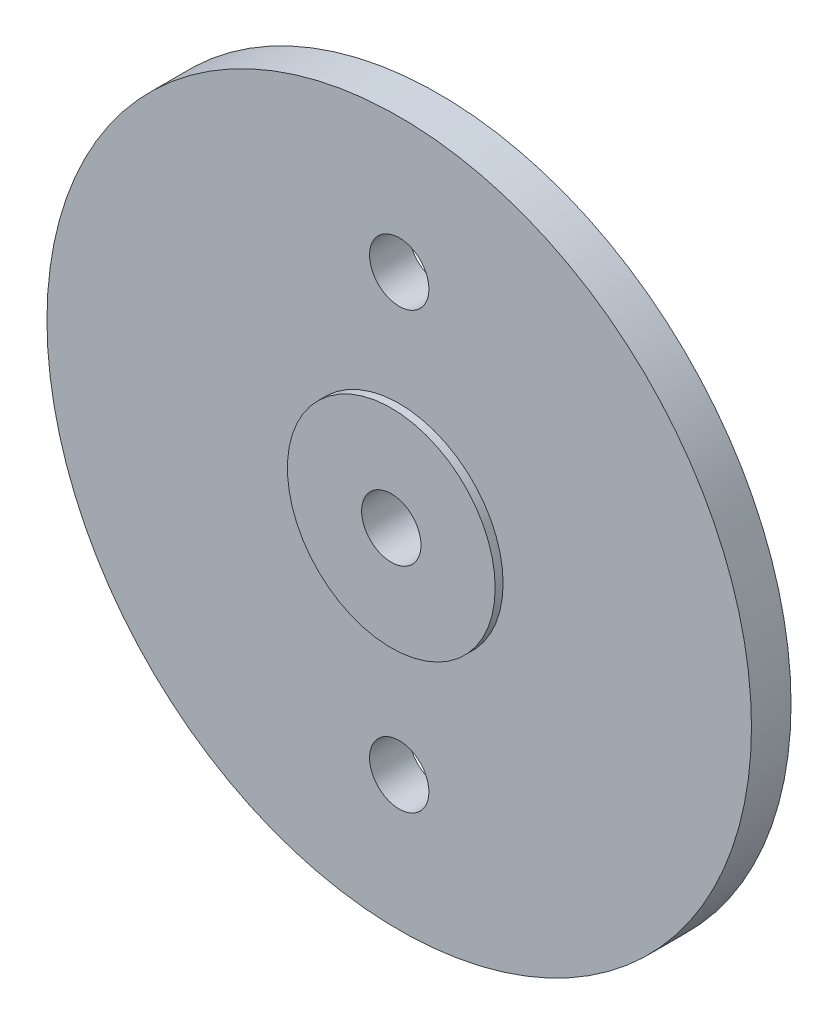
from build123d import *

# Parameters (mm, degrees)
SKETCH_1_R          = 17.8
EXTRUDE_1_DEPTH     = 2
SKETCH_2_R          = 7.85
EXTRUDE_2_DEPTH     = 0.8
DRAFT_1_ANGLE       = 1
SKETCH_38_R         = 4.8
EXTRUDE_3_DEPTH     = 1.9
SKETCH_39_R         = 5.25
EXTRUDE_4_DEPTH     = 0.4
SKETCH_40_R         = 1.5
CUT_EXTRUDE_1_DEPTH = 10.4
SKETCH_42_R         = 1.5
CUT_EXTRUDE_3_DEPTH = 10


with BuildPart() as part:
    # ｽｹｯﾁ1 → ﾎﾞｽ - 押し出し1 (new body)
    with BuildSketch(Plane.XY):
        Circle(SKETCH_1_R)
    extrude(amount=EXTRUDE_1_DEPTH)

    # ｽｹｯﾁ2 → ﾎﾞｽ - 押し出し2 (add)
    with BuildSketch(Plane(origin=(0, 0, 0), x_dir=(-1, 0, 0), z_dir=(0, 0, -1))):
        Circle(SKETCH_2_R)
    extrude(amount=EXTRUDE_2_DEPTH)

    # 抜き勾配1
    draft_1_faces = [part.faces().sort_by_distance(p)[0] for p in [
        (7.85, 0, -0.4),
    ]]
    draft(draft_1_faces, Plane(origin=(0, 0, -0.8), x_dir=(-1, 0, 0), z_dir=(0, 0, -1)), DRAFT_1_ANGLE)

    # ｽｹｯﾁ38 → ﾎﾞｽ - 押し出し3 (add)
    with BuildSketch(Plane(origin=(0, 0, -0.8), x_dir=(-1, 0, 0), z_dir=(0, 0, -1))):
        Circle(SKETCH_38_R)
    extrude(amount=EXTRUDE_3_DEPTH)

    # ｽｹｯﾁ39 → ﾎﾞｽ - 押し出し4 (add)
    with BuildSketch(Plane.XY.offset(2)):
        Circle(SKETCH_39_R)
    extrude(amount=EXTRUDE_4_DEPTH)

    # ｽｹｯﾁ40 → ｶｯﾄ - 押し出し1 (cut)
    with BuildSketch(Plane.XY.offset(2.4)):
        Circle(SKETCH_40_R)
    extrude(amount=-CUT_EXTRUDE_1_DEPTH, mode=Mode.SUBTRACT)

    # ｽｹｯﾁ42 → ｶｯﾄ - 押し出し3 (cut)
    with BuildSketch(Plane.XY.offset(2)):
        with Locations((0, 11)):
            Circle(SKETCH_42_R)
        with Locations((0, -11)):
            Circle(SKETCH_42_R)
    extrude(amount=-CUT_EXTRUDE_3_DEPTH, mode=Mode.SUBTRACT)


solid = part.part
